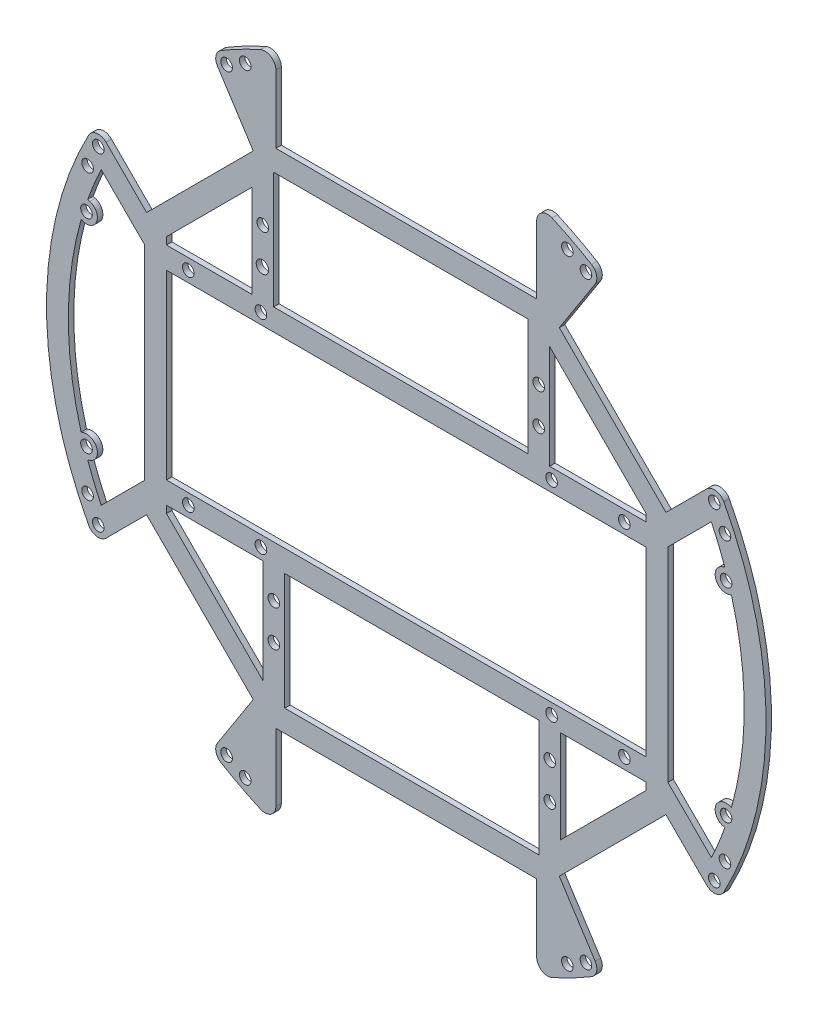
from build123d import *

# Parameters (mm, degrees)
SKETCH1_R            = 1.4
SKETCH1_R_2          = 1.6
SKETCH1_R_3          = 56
BOSS_EXTRUDE2_DEPTH  = 1.5
BOSS_EXTRUDE3_DEPTH  = 1.5
SKETCH3_R            = 1.6
CUT_EXTRUDE1_DEPTH   = 10
SKETCH4_R            = 1.6
BOSS_EXTRUDE4_DEPTH  = 1.5
FILLET1_R            = 3
SKETCH5_R            = 1.6
BOSS_EXTRUDE5_DEPTH  = 1.5
SKETCH6_R            = 1.6
CUT_EXTRUDE2_DEPTH   = 1.5
CUT_EXTRUDE3_DEPTH   = 10
SKETCH8_R            = 1.4
BOSS_EXTRUDE6_DEPTH  = 1.5
SKETCH9_W            = 144
SKETCH9_H            = 6
BOSS_EXTRUDE7_DEPTH  = 1.5
BOSS_EXTRUDE8_DEPTH  = 1.5
SKETCH11_W           = 71.777589622
SKETCH11_H           = 10.305965164
CUT_EXTRUDE4_DEPTH   = 41
SKETCH12_W           = 71.777589622
SKETCH12_H           = 6
BOSS_EXTRUDE9_DEPTH  = 1.5
SKETCH13_W           = 6
SKETCH13_H           = 51.475780146
SKETCH13_H_2         = 46.82423944
BOSS_EXTRUDE10_DEPTH = 1.5
SKETCH14_W           = 66
SKETCH14_H           = 6
CUT_EXTRUDE5_DEPTH   = 41
BOSS_EXTRUDE11_DEPTH = 1.5
SKETCH16_R           = 1.6
CUT_EXTRUDE6_DEPTH   = 5
SKETCH17_R           = 1.6
CUT_EXTRUDE7_DEPTH   = 5
SKETCH18_R           = 1.6
BOSS_EXTRUDE14_DEPTH = 1.5
BOSS_EXTRUDE15_DEPTH = 1.5
SKETCH21_W           = 1.5
SKETCH21_H           = 32.106154556
BOSS_EXTRUDE16_DEPTH = 1.5
SKETCH22_R           = 1.6
SKETCH22_R_2         = 1.7
CUT_EXTRUDE9_DEPTH   = 1.5
BOSS_EXTRUDE17_DEPTH = 1.5
SKETCH24_R           = 1.6
CUT_EXTRUDE10_DEPTH  = 1.5
SKETCH25_R           = 1.6
BOSS_EXTRUDE18_DEPTH = 1.5
SKETCH26_R           = 1.6
CUT_EXTRUDE11_DEPTH  = 1.5
SKETCH28_R           = 1.6
CUT_EXTRUDE12_DEPTH  = 1.5
SKETCH29_R           = 1.6
BOSS_EXTRUDE19_DEPTH = 1.5
SKETCH30_W           = 4.95
SKETCH30_H           = 32.106154556
SKETCH30_W_2         = 1.5
CUT_EXTRUDE13_DEPTH  = 1.5
BOSS_EXTRUDE20_DEPTH = 1.5


with BuildPart() as part:
    # Sketch1 → Boss-Extrude2 (new body)
    with BuildSketch(Plane.XY):
        with BuildLine():
            Line((-35.888794811, 73.41211972), (-35.888794811, 92.265889727))
            ThreePointArc((-35.888794811, 92.265889727), (-42.061063674, 89.620683565), (-48.039811225, 86.563136135))
            Line((-48.039811225, 86.563136135), (-41.888794811, 80.41211972))
            Line((-41.888794811, 80.41211972), (-41.888794811, 65.59143593))
            Line((-41.888794811, 65.59143593), (-53.74011537, 53.74011537))
            Line((-53.74011537, 53.74011537), (-65.053823869, 42.426406871))
            Line((-65.053823869, 42.426406871), (-71.46564447, 36.01458627))
            Line((-71.46564447, 36.01458627), (-82.641648571, 47.190590371))
            ThreePointArc((-82.641648571, 47.190590371), (-85.206397148, 48.036317618), (-87.411811693, 46.477684716))
            ThreePointArc((-87.411811693, 46.477684716), (-99, 0), (-87.411811693, -46.477684716))
            ThreePointArc((-87.411811693, -46.477684716), (-85.206397148, -48.036317618), (-82.641648571, -47.190590371))
            Line((-82.641648571, -47.190590371), (-71.46564447, -36.01458627))
            Line((-71.46564447, -36.01458627), (-65.053823869, -42.426406871))
            Line((-65.053823869, -42.426406871), (-53.74011537, -53.74011537))
            Line((-53.74011537, -53.74011537), (-41.888794811, -65.59143593))
            Line((-41.888794811, -65.59143593), (-41.888794811, -80.41211972))
            Line((-41.888794811, -80.41211972), (-48.039811225, -86.563136135))
            ThreePointArc((-48.039811225, -86.563136135), (-42.061063674, -89.620683565), (-35.888794811, -92.265889727))
            Line((-35.888794811, -92.265889727), (-35.888794811, -73.41211972))
            Line((-35.888794811, -73.41211972), (35.888794811, -73.41211972))
            Line((35.888794811, -73.41211972), (35.888794811, -92.265889727))
            ThreePointArc((35.888794811, -92.265889727), (42.061063674, -89.620683565), (48.039811225, -86.563136135))
            Line((48.039811225, -86.563136135), (41.888794811, -80.41211972))
            Line((41.888794811, -80.41211972), (41.888794811, -65.59143593))
            Line((41.888794811, -65.59143593), (53.74011537, -53.74011537))
            Line((53.74011537, -53.74011537), (65.053823869, -42.426406871))
            Line((65.053823869, -42.426406871), (71.46564447, -36.01458627))
            Line((71.46564447, -36.01458627), (82.641648571, -47.190590371))
            ThreePointArc((82.641648571, -47.190590371), (85.206397148, -48.036317618), (87.411811693, -46.477684716))
            ThreePointArc((87.411811693, -46.477684716), (99, 0), (87.411811693, 46.477684716))
            ThreePointArc((87.411811693, 46.477684716), (85.206397148, 48.036317618), (82.641648571, 47.190590371))
            Line((82.641648571, 47.190590371), (71.46564447, 36.01458627))
            Line((71.46564447, 36.01458627), (65.053823869, 42.426406871))
            Line((65.053823869, 42.426406871), (53.74011537, 53.74011537))
            Line((53.74011537, 53.74011537), (41.888794811, 65.59143593))
            Line((41.888794811, 65.59143593), (41.888794811, 80.41211972))
            Line((41.888794811, 80.41211972), (48.039811225, 86.563136135))
            ThreePointArc((48.039811225, 86.563136135), (42.061063674, 89.620683565), (35.888794811, 92.265889727))
            Line((35.888794811, 92.265889727), (35.888794811, 73.41211972))
            Line((35.888794811, 73.41211972), (-35.888794811, 73.41211972))
        make_face()
        with Locations((-36.062445841, 54.447222151)):
            Circle(SKETCH1_R, mode=Mode.SUBTRACT)
        with Locations((-54.447222151, 36.062445841)):
            Circle(SKETCH1_R, mode=Mode.SUBTRACT)
        with Locations((-60.104076401, 41.71930009)):
            Circle(SKETCH1_R, mode=Mode.SUBTRACT)
        with Locations((-41.71930009, 60.104076401)):
            Circle(SKETCH1_R, mode=Mode.SUBTRACT)
        with Locations((41.365746699, 41.365746699)):
            Circle(SKETCH1_R_2, mode=Mode.SUBTRACT)
        with Locations((41.71930009, 60.104076401)):
            Circle(SKETCH1_R, mode=Mode.SUBTRACT)
        with Locations((60.104076401, 41.71930009)):
            Circle(SKETCH1_R, mode=Mode.SUBTRACT)
        with Locations((54.447222151, 36.062445841)):
            Circle(SKETCH1_R, mode=Mode.SUBTRACT)
        Circle(SKETCH1_R_3, mode=Mode.SUBTRACT)
        with Locations((36.062445841, 54.447222151)):
            Circle(SKETCH1_R, mode=Mode.SUBTRACT)
        with Locations((-40.571353127, 87.005547556)):
            Circle(SKETCH1_R_2, mode=Mode.SUBTRACT)
        with Locations((40.571353127, -87.005547556)):
            Circle(SKETCH1_R_2, mode=Mode.SUBTRACT)
        with Locations((-40.571353127, -87.005547556)):
            Circle(SKETCH1_R_2, mode=Mode.SUBTRACT)
        with Locations((41.365746699, -41.365746699)):
            Circle(SKETCH1_R_2, mode=Mode.SUBTRACT)
        with Locations((-41.365746699, 41.365746699)):
            Circle(SKETCH1_R_2, mode=Mode.SUBTRACT)
        with Locations((-84.762968914, 45.069270027)):
            Circle(SKETCH1_R_2, mode=Mode.SUBTRACT)
        with Locations((-41.365746699, -41.365746699)):
            Circle(SKETCH1_R_2, mode=Mode.SUBTRACT)
        with Locations((84.762968914, 45.069270027)):
            Circle(SKETCH1_R_2, mode=Mode.SUBTRACT)
        with Locations((40.571353127, 87.005547556)):
            Circle(SKETCH1_R_2, mode=Mode.SUBTRACT)
        with Locations((36.062445841, -54.447222151)):
            Circle(SKETCH1_R, mode=Mode.SUBTRACT)
        with Locations((54.447222151, -36.062445841)):
            Circle(SKETCH1_R, mode=Mode.SUBTRACT)
        with Locations((60.104076401, -41.71930009)):
            Circle(SKETCH1_R, mode=Mode.SUBTRACT)
        with Locations((41.71930009, -60.104076401)):
            Circle(SKETCH1_R, mode=Mode.SUBTRACT)
        with Locations((-41.71930009, -60.104076401)):
            Circle(SKETCH1_R, mode=Mode.SUBTRACT)
        with Locations((-60.104076401, -41.71930009)):
            Circle(SKETCH1_R, mode=Mode.SUBTRACT)
        with Locations((-54.447222151, -36.062445841)):
            Circle(SKETCH1_R, mode=Mode.SUBTRACT)
        with Locations((-36.062445841, -54.447222151)):
            Circle(SKETCH1_R, mode=Mode.SUBTRACT)
        with Locations((84.762968914, -45.069270027)):
            Circle(SKETCH1_R_2, mode=Mode.SUBTRACT)
        with Locations((-84.762968914, -45.069270027)):
            Circle(SKETCH1_R_2, mode=Mode.SUBTRACT)
        with BuildLine():
            Line((-56.568542495, 42.426406871), (-49.621038435, 35.478902811))
            ThreePointArc((-49.621038435, 35.478902811), (-43.133513652, 43.133513652), (-35.478902811, 49.621038435))
            Line((-35.478902811, 49.621038435), (-42.426406871, 56.568542495))
            Line((-42.426406871, 56.568542495), (-56.568542495, 42.426406871))
        make_face(mode=Mode.SUBTRACT)
        with BuildLine():
            Line((-57.337431152, 34.710014154), (-52.937019276, 30.309602278))
            ThreePointArc((-52.937019276, 30.309602278), (-61, 0), (-52.937019276, -30.309602278))
            Line((-52.937019276, -30.309602278), (-57.337431152, -34.710014154))
            Line((-57.337431152, -34.710014154), (-60.811183182, -38.183766184))
            Line((-60.811183182, -38.183766184), (-71.46564447, -27.529304896))
            Line((-71.46564447, -27.529304896), (-83.951228087, -40.014888513))
            ThreePointArc((-83.951228087, -40.014888513), (-93, 0), (-83.951228087, 40.014888513))
            Line((-83.951228087, 40.014888513), (-71.46564447, 27.529304896))
            Line((-71.46564447, 27.529304896), (-60.811183182, 38.183766184))
            Line((-60.811183182, 38.183766184), (-57.337431152, 34.710014154))
        make_face(mode=Mode.SUBTRACT)
        with BuildLine():
            Line((-35.888794811, 67.41211972), (-35.888794811, 58.516211808))
            Line((-35.888794811, 58.516211808), (-30.309602278, 52.937019275))
            ThreePointArc((-30.309602278, 52.937019275), (0, 61), (30.309602278, 52.937019275))
            Line((30.309602278, 52.937019275), (35.888794811, 58.516211808))
            Line((35.888794811, 58.516211808), (35.888794811, 67.41211972))
            Line((35.888794811, 67.41211972), (0, 67.41211972))
            Line((0, 67.41211972), (-35.888794811, 67.41211972))
        make_face(mode=Mode.SUBTRACT)
        with BuildLine():
            Line((60.811183182, 38.183766184), (71.46564447, 27.529304896))
            Line((71.46564447, 27.529304896), (83.951228087, 40.014888513))
            ThreePointArc((83.951228087, 40.014888513), (93, 0), (83.951228087, -40.014888513))
            Line((83.951228087, -40.014888513), (71.46564447, -27.529304896))
            Line((71.46564447, -27.529304896), (60.811183182, -38.183766184))
            Line((60.811183182, -38.183766184), (57.337431152, -34.710014154))
            Line((57.337431152, -34.710014154), (52.937019276, -30.309602278))
            ThreePointArc((52.937019276, -30.309602278), (61, 0), (52.937019276, 30.309602278))
            Line((52.937019276, 30.309602278), (57.337431152, 34.710014154))
            Line((57.337431152, 34.710014154), (60.811183182, 38.183766184))
        make_face(mode=Mode.SUBTRACT)
        with BuildLine():
            Line((42.426406871, 56.568542495), (56.568542495, 42.426406871))
            Line((56.568542495, 42.426406871), (49.621038435, 35.478902811))
            ThreePointArc((49.621038435, 35.478902811), (43.133513652, 43.133513652), (35.478902811, 49.621038435))
            Line((35.478902811, 49.621038435), (42.426406871, 56.568542495))
        make_face(mode=Mode.SUBTRACT)
        with BuildLine():
            Line((0, -67.41211972), (35.888794811, -67.41211972))
            Line((35.888794811, -67.41211972), (35.888794811, -58.516211808))
            Line((35.888794811, -58.516211808), (30.309602278, -52.937019275))
            ThreePointArc((30.309602278, -52.937019275), (0, -61), (-30.309602278, -52.937019275))
            Line((-30.309602278, -52.937019275), (-35.888794811, -58.516211808))
            Line((-35.888794811, -58.516211808), (-35.888794811, -67.41211972))
            Line((-35.888794811, -67.41211972), (0, -67.41211972))
        make_face(mode=Mode.SUBTRACT)
        with BuildLine():
            Line((56.568542495, -42.426406871), (49.621038435, -35.478902811))
            ThreePointArc((49.621038435, -35.478902811), (43.133513652, -43.133513652), (35.478902811, -49.621038435))
            Line((35.478902811, -49.621038435), (42.426406871, -56.568542495))
            Line((42.426406871, -56.568542495), (56.568542495, -42.426406871))
        make_face(mode=Mode.SUBTRACT)
        with BuildLine():
            Line((-42.426406871, -56.568542495), (-56.568542495, -42.426406871))
            Line((-56.568542495, -42.426406871), (-49.621038435, -35.478902811))
            ThreePointArc((-49.621038435, -35.478902811), (-43.133513652, -43.133513652), (-35.478902811, -49.621038435))
            Line((-35.478902811, -49.621038435), (-42.426406871, -56.568542495))
        make_face(mode=Mode.SUBTRACT)
    extrude(amount=BOSS_EXTRUDE2_DEPTH)

    # Sketch2 → Boss-Extrude3 (add)
    with BuildSketch(Plane.XY.offset(1.5)):
        with BuildLine():
            Line((-41.888794811, 80.41211972), (-41.888794811, 78.41211972))
            Line((-41.888794811, 78.41211972), (-49.31800671, 85.841331619))
            ThreePointArc((-49.31800671, 85.841331619), (-47.440229793, 86.893179233), (-45.540030314, 87.903956902))
            Line((-45.540030314, 87.903956902), (-41.888794811, 84.252721398))
            Line((-41.888794811, 84.252721398), (-41.888794811, 80.41211972))
        make_face()
        with BuildLine():
            Line((41.888794811, 84.252721398), (45.540030314, 87.903956902))
            ThreePointArc((45.540030314, 87.903956902), (47.440229793, 86.893179233), (49.31800671, 85.841331619))
            Line((49.31800671, 85.841331619), (41.888794811, 78.41211972))
            Line((41.888794811, 78.41211972), (41.888794811, 80.41211972))
            Line((41.888794811, 80.41211972), (41.888794811, 84.252721398))
        make_face()
        with BuildLine():
            Line((41.888794811, -80.41211972), (41.888794811, -78.41211972))
            Line((41.888794811, -78.41211972), (49.31800671, -85.841331619))
            ThreePointArc((49.31800671, -85.841331619), (47.440229793, -86.893179233), (45.540030314, -87.903956902))
            Line((45.540030314, -87.903956902), (41.888794811, -84.252721398))
            Line((41.888794811, -84.252721398), (41.888794811, -80.41211972))
        make_face()
        with BuildLine():
            Line((-41.888794811, -84.252721398), (-45.540030314, -87.903956902))
            ThreePointArc((-45.540030314, -87.903956902), (-47.440229793, -86.893179233), (-49.31800671, -85.841331619))
            Line((-49.31800671, -85.841331619), (-41.888794811, -78.41211972))
            Line((-41.888794811, -78.41211972), (-41.888794811, -80.41211972))
            Line((-41.888794811, -80.41211972), (-41.888794811, -84.252721398))
        make_face()
    extrude(amount=-BOSS_EXTRUDE3_DEPTH)

    # Sketch3 → Cut-Extrude1 (cut)
    with BuildSketch(Plane.XY.offset(1.5)):
        with Locations((-44.327866871, 85.153039985)):
            Circle(SKETCH3_R)
        with Locations((44.327866871, 85.153039985)):
            Circle(SKETCH3_R)
        with Locations((44.327866871, -85.153039985)):
            Circle(SKETCH3_R)
        with Locations((-44.327866871, -85.153039985)):
            Circle(SKETCH3_R)
    extrude(amount=-CUT_EXTRUDE1_DEPTH, mode=Mode.SUBTRACT)

    # Sketch4 → Boss-Extrude4 (add)
    with BuildSketch(Plane.XY.offset(1.5)):
        with Locations((-40.571353127, 87.005547556)):
            Circle(SKETCH4_R)
        with Locations((40.571353127, 87.005547556)):
            Circle(SKETCH4_R)
        with Locations((40.571353127, -87.005547556)):
            Circle(SKETCH4_R)
        with Locations((-40.571353127, -87.005547556)):
            Circle(SKETCH4_R)
    extrude(amount=-BOSS_EXTRUDE4_DEPTH)

    # Fillet1
    fillet1_edges = [part.edges().sort_by_distance(p)[0] for p in [
        (35.888794811, -92.265889727, 0.75),
        (-35.888794811, -92.265889727, 0.75),
        (-35.888794811, 92.265889727, 0.75),
        (35.888794811, 92.265889727, 0.75),
        (49.31800671, 85.841331619, 0.75),
        (-49.31800671, 85.841331619, 0.75),
        (49.31800671, -85.841331619, 0.75),
        (-49.31800671, -85.841331619, 0.75),
    ]]
    fillet(fillet1_edges, radius=FILLET1_R)

    # Sketch5 → Boss-Extrude5 (add)
    with BuildSketch(Plane.XY.offset(1.5)):
        with BuildLine():
            ThreePointArc((-7, 66.41211972), (-10, 63.41211972), (-13, 66.41211972))
            Line((-13, 66.41211972), (-13, 67.41211972))
            Line((-13, 67.41211972), (-9.775161328, 70.187281048))
            Line((-9.775161328, 70.187281048), (-7, 67.41211972))
            Line((-7, 67.41211972), (-7, 66.41211972))
        make_face()
        with Locations((-10, 66.41211972)):
            Circle(SKETCH5_R, mode=Mode.SUBTRACT)
        with BuildLine():
            Line((7, 66.41211972), (7, 67.41211972))
            Line((7, 67.41211972), (9.775161328, 70.187281048))
            Line((9.775161328, 70.187281048), (13, 67.41211972))
            Line((13, 67.41211972), (13, 66.41211972))
            ThreePointArc((13, 66.41211972), (10, 63.41211972), (7, 66.41211972))
        make_face()
        with Locations((10, 66.41211972)):
            Circle(SKETCH5_R, mode=Mode.SUBTRACT)
        with BuildLine():
            ThreePointArc((7, -66.41211972), (10, -63.41211972), (13, -66.41211972))
            Line((13, -66.41211972), (13, -67.41211972))
            Line((13, -67.41211972), (9.775161328, -70.187281048))
            Line((9.775161328, -70.187281048), (7, -67.41211972))
            Line((7, -67.41211972), (7, -66.41211972))
        make_face()
        with Locations((10, -66.41211972)):
            Circle(SKETCH5_R, mode=Mode.SUBTRACT)
        with BuildLine():
            Line((-7, -66.41211972), (-7, -67.41211972))
            Line((-7, -67.41211972), (-9.775161328, -70.187281048))
            Line((-9.775161328, -70.187281048), (-13, -67.41211972))
            Line((-13, -67.41211972), (-13, -66.41211972))
            ThreePointArc((-13, -66.41211972), (-10, -63.41211972), (-7, -66.41211972))
        make_face()
        with Locations((-10, -66.41211972)):
            Circle(SKETCH5_R, mode=Mode.SUBTRACT)
    extrude(amount=-BOSS_EXTRUDE5_DEPTH)

    # Sketch6 → Cut-Extrude2 (cut)
    with BuildSketch(Plane.XY.offset(1.5)):
        with Locations((-10, -66.41211972)):
            Circle(SKETCH6_R)
        with Locations((10, -66.41211972)):
            Circle(SKETCH6_R)
        with Locations((10, 66.41211972)):
            Circle(SKETCH6_R)
        with Locations((-10, 66.41211972)):
            Circle(SKETCH6_R)
    extrude(amount=-CUT_EXTRUDE2_DEPTH, mode=Mode.SUBTRACT)

    # Sketch7 → Cut-Extrude3 (cut)
    with BuildSketch(Plane.XY.offset(1.5)):
        Polygon((-71.46564447, 27.529304896), (-31.582829646, 67.41211972), (31.582829646, 67.41211972), (71.46564447, 27.529304896), (71.46564447, -27.529304896), (31.582829646, -67.41211972), (-31.582829646, -67.41211972), (-71.46564447, -27.529304896), align=None)
    extrude(amount=-CUT_EXTRUDE3_DEPTH, mode=Mode.SUBTRACT)

    # Sketch8 → Boss-Extrude6 (add)
    with BuildSketch(Plane.XY.offset(1.5)):
        with Locations((-60.104076401, -41.71930009)):
            Circle(SKETCH8_R)
        with Locations((-41.71930009, -60.104076401)):
            Circle(SKETCH8_R)
        with Locations((-60.104076401, 41.71930009)):
            Circle(SKETCH8_R)
        with Locations((-41.71930009, 60.104076401)):
            Circle(SKETCH8_R)
        with Locations((41.71930009, 60.104076401)):
            Circle(SKETCH8_R)
        with Locations((60.104076401, 41.71930009)):
            Circle(SKETCH8_R)
        with Locations((60.104076401, -41.71930009)):
            Circle(SKETCH8_R)
        with Locations((41.71930009, -60.104076401)):
            Circle(SKETCH8_R)
        Polygon((-23.568897205, -67.41211972), (23.568897205, -67.41211972), (18.047381119, -71.229666129), (-16.662853075, -71.229666129), align=None)
        Polygon((23.568897205, 67.41211972), (-26.29313108, 67.41211972), (-20.11587514, 71.683041123), (11.2489996, 71.683041123), align=None)
    extrude(amount=-BOSS_EXTRUDE6_DEPTH)

    # Sketch9 → Boss-Extrude7 (add)
    with BuildSketch(Plane.XY.offset(1.5)):
        with Locations((0, 26.41211972)):
            Rectangle(SKETCH9_W, SKETCH9_H)
        with Locations((0, -26.41211972)):
            Rectangle(SKETCH9_W, SKETCH9_H)
    extrude(amount=-BOSS_EXTRUDE7_DEPTH)

    # Sketch10 → Boss-Extrude8 (add)
    with BuildSketch(Plane.XY.offset(1.5)):
        Polygon((-72, 23.41211972), (-66, 23.41211972), (-66, 35.490217447), (-72, 28.063660426), align=None)
        Polygon((72, 28.063660426), (72, 23.41211972), (66, 23.41211972), (66, 35.490217447), align=None)
        Polygon((72, -23.41211972), (66, -23.41211972), (66, -35.490217447), (72, -28.063660426), align=None)
        Polygon((-72, -28.063660426), (-72, -23.41211972), (-66, -23.41211972), (-66, -35.490217447), align=None)
    extrude(amount=-BOSS_EXTRUDE8_DEPTH)

    # Sketch11 → Cut-Extrude4 (cut)
    with BuildSketch(Plane.XY.offset(1.5)):
        with Locations((0, 68.259137138)):
            Rectangle(SKETCH11_W, SKETCH11_H)
        with Locations((0, -68.259137138)):
            Rectangle(SKETCH11_W, SKETCH11_H)
    extrude(amount=-CUT_EXTRUDE4_DEPTH, mode=Mode.SUBTRACT)

    # Sketch12 → Boss-Extrude9 (add)
    with BuildSketch(Plane.XY.offset(1.5)):
        with Locations((0, 66.106154556)):
            Rectangle(SKETCH12_W, SKETCH12_H)
        with Locations((0, -66.106154556)):
            Rectangle(SKETCH12_W, SKETCH12_H)
    extrude(amount=-BOSS_EXTRUDE9_DEPTH)

    # Sketch13 → Boss-Extrude10 (add)
    with BuildSketch(Plane.XY.offset(1.5)):
        with Locations((-69, -2.325770353)):
            Rectangle(SKETCH13_W, SKETCH13_H)
        with Locations((69, 0)):
            Rectangle(SKETCH13_W, SKETCH13_H_2)
    extrude(amount=-BOSS_EXTRUDE10_DEPTH)

    # Sketch14 → Cut-Extrude5 (cut)
    with BuildSketch(Plane.XY.offset(1.5)):
        with Locations((33, 26.41211972)):
            Rectangle(SKETCH14_W, SKETCH14_H)
        with Locations((-33, 26.41211972)):
            Rectangle(SKETCH14_W, SKETCH14_H)
        with Locations((-33, -26.41211972)):
            Rectangle(SKETCH14_W, SKETCH14_H)
        with Locations((33, -26.41211972)):
            Rectangle(SKETCH14_W, SKETCH14_H)
    extrude(amount=-CUT_EXTRUDE5_DEPTH, mode=Mode.SUBTRACT)

    # Sketch15 → Boss-Extrude11 (add)
    with BuildSketch(Plane.XY.offset(1.5)):
        Polygon((-66, -25), (0, -25), (66, -25), (66, -31), (-66, -31), align=None)
        Polygon((0, 25), (66, 25), (66, 31), (-66, 31), (-66, 25), align=None)
    extrude(amount=-BOSS_EXTRUDE11_DEPTH)

    # Sketch16 → Cut-Extrude6 (cut)
    with BuildSketch(Plane.XY.offset(1.5)):
        with Locations((60, 28)):
            Circle(SKETCH16_R)
        with Locations((-60, 28)):
            Circle(SKETCH16_R)
        with Locations((-60, -28)):
            Circle(SKETCH16_R)
        with Locations((60, -28)):
            Circle(SKETCH16_R)
    extrude(amount=-CUT_EXTRUDE6_DEPTH, mode=Mode.SUBTRACT)

    # Sketch17 → Cut-Extrude7 (cut)
    with BuildSketch(Plane.XY.offset(1.5)):
        with Locations((-40, 28)):
            Circle(SKETCH17_R)
        with Locations((40, 28)):
            Circle(SKETCH17_R)
        with Locations((40, -28)):
            Circle(SKETCH17_R)
        with Locations((-40, -28)):
            Circle(SKETCH17_R)
    extrude(amount=-CUT_EXTRUDE7_DEPTH, mode=Mode.SUBTRACT)

    # Sketch18 → Boss-Extrude14 (add)
    with BuildSketch(Plane.XY.offset(1.5)):
        Polygon((34.5, 63.106154556), (34.5, 31), (31.5, 31), (28.5, 31), (28.5, 63.106154556), align=None)
        with Locations((31.5, 49)):
            Circle(SKETCH18_R, mode=Mode.SUBTRACT)
        with Locations((31.5, 39)):
            Circle(SKETCH18_R, mode=Mode.SUBTRACT)
        Polygon((-34.5, -63.106154556), (-34.5, -31), (-31.5, -31), (-28.5, -31), (-28.5, -63.106154556), align=None)
        with Locations((-31.5, -49)):
            Circle(SKETCH18_R, mode=Mode.SUBTRACT)
        with Locations((-31.5, -39)):
            Circle(SKETCH18_R, mode=Mode.SUBTRACT)
    extrude(amount=-BOSS_EXTRUDE14_DEPTH)

    # Sketch19 → Boss-Extrude15 (add)
    with BuildSketch(Plane.XY.offset(1.5)):
        Polygon((-38, 31), (-35, 31), (-35, 63.106154556), (-35.888794811, 63.106154556), (-41, 57.994949366), (-41, 31), align=None)
        with BuildLine():
            ThreePointArc((-36.4, 39), (-36.86862915, 37.86862915), (-38, 37.4))
            ThreePointArc((-38, 37.4), (-39.6, 39), (-38, 40.6))
            ThreePointArc((-38, 40.6), (-36.86862915, 40.13137085), (-36.4, 39))
        make_face(mode=Mode.SUBTRACT)
        with BuildLine():
            ThreePointArc((-36.4, 49), (-36.86862915, 47.86862915), (-38, 47.4))
            ThreePointArc((-38, 47.4), (-39.13137085, 50.13137085), (-36.4, 49))
        make_face(mode=Mode.SUBTRACT)
        Polygon((38, -31), (35, -31), (35, -63.106154556), (35.888794811, -63.106154556), (41, -57.994949366), (41, -31), align=None)
        with BuildLine():
            ThreePointArc((39.6, -49), (36.86862915, -50.13137085), (38, -47.4))
            ThreePointArc((38, -47.4), (39.13137085, -47.86862915), (39.6, -49))
        make_face(mode=Mode.SUBTRACT)
        with BuildLine():
            ThreePointArc((38, -40.6), (36.4, -39), (38, -37.4))
            ThreePointArc((38, -37.4), (39.13137085, -37.86862915), (39.6, -39))
            ThreePointArc((39.6, -39), (39.13137085, -40.13137085), (38, -40.6))
        make_face(mode=Mode.SUBTRACT)
    extrude(amount=-BOSS_EXTRUDE15_DEPTH)

    # Sketch21 → Boss-Extrude16 (add)
    with BuildSketch(Plane.XY.offset(1.5)):
        with BuildLine():
            ThreePointArc((-32.25, -40.413329403), (-31.4, -39), (-32.25, -37.586670597))
            ThreePointArc((-32.25, -37.586670597), (-29.9, -39), (-32.25, -40.413329403))
        make_face()
        with BuildLine():
            ThreePointArc((-32.25, -50.413329403), (-31.4, -49), (-32.25, -47.586670597))
            ThreePointArc((-32.25, -47.586670597), (-29.9, -49), (-32.25, -50.413329403))
        make_face()
        with Locations((-35.25, -47.053077278)):
            Rectangle(SKETCH21_W, SKETCH21_H)
        Polygon((42.5, -56.494949366), (41, -57.994949366), (41, -31), (42.5, -31), align=None)
        with BuildLine():
            ThreePointArc((38.75, -50.413329403), (36.4, -49), (38.75, -47.586670597))
            ThreePointArc((38.75, -47.586670597), (37.9, -49), (38.75, -50.413329403))
        make_face()
        with BuildLine():
            ThreePointArc((38.75, -40.413329403), (36.4, -39), (38.75, -37.586670597))
            ThreePointArc((38.75, -37.586670597), (37.9, -39), (38.75, -40.413329403))
        make_face()
        with Locations((35.25, 47.053077278)):
            Rectangle(SKETCH21_W, SKETCH21_H)
        with BuildLine():
            ThreePointArc((32.25, 47.586670597), (29.9, 49), (32.25, 50.413329403))
            ThreePointArc((32.25, 50.413329403), (31.4, 49), (32.25, 47.586670597))
        make_face()
        with BuildLine():
            ThreePointArc((32.25, 37.586670597), (29.9, 39), (32.25, 40.413329403))
            ThreePointArc((32.25, 40.413329403), (31.4, 39), (32.25, 37.586670597))
        make_face()
        with BuildLine():
            ThreePointArc((-38.75, 47.586670597), (-37.9, 49), (-38.75, 50.413329403))
            ThreePointArc((-38.75, 50.413329403), (-36.4, 49), (-38.75, 47.586670597))
        make_face()
        with BuildLine():
            ThreePointArc((-38.75, 37.586670597), (-37.9, 39), (-38.75, 40.413329403))
            ThreePointArc((-38.75, 40.413329403), (-36.4, 39), (-38.75, 37.586670597))
        make_face()
        Polygon((-41, 57.994949366), (-41, 31), (-42.5, 31), (-42.5, 56.494949366), align=None)
    extrude(amount=-BOSS_EXTRUDE16_DEPTH)

    # Sketch22 → Cut-Extrude9 (cut)
    with BuildSketch(Plane.XY.offset(1.5)):
        with Locations((-39.5, 49)):
            Circle(SKETCH22_R)
        with Locations((-39.6, 39)):
            Circle(SKETCH22_R_2)
        with Locations((33, 49)):
            Circle(SKETCH22_R)
        with Locations((33, 39)):
            Circle(SKETCH22_R)
        with Locations((-33, -39)):
            Circle(SKETCH22_R)
        with Locations((-33, -49)):
            Circle(SKETCH22_R)
        with Locations((39.5, -39)):
            Circle(SKETCH22_R)
        with Locations((39.5, -49)):
            Circle(SKETCH22_R)
    extrude(amount=-CUT_EXTRUDE9_DEPTH, mode=Mode.SUBTRACT)

    # Sketch23 → Boss-Extrude17 (add)
    with BuildSketch(Plane.XY.offset(1.5)):
        Polygon((36, 31), (39.45, 31), (39.45, 59.544949366), (36, 62.994949366), align=None)
        Polygon((-36, -31), (-39.45, -31), (-39.45, -59.544949366), (-36, -62.994949366), align=None)
    extrude(amount=-BOSS_EXTRUDE17_DEPTH)

    # Sketch24 → Cut-Extrude10 (cut)
    with BuildSketch(Plane.XY.offset(1.5)):
        with Locations((-36.45, -49)):
            Circle(SKETCH24_R)
        with Locations((-36.45, -39)):
            Circle(SKETCH24_R)
        with Locations((36.45, 49)):
            Circle(SKETCH24_R)
        with Locations((36.45, 39)):
            Circle(SKETCH24_R)
    extrude(amount=-CUT_EXTRUDE10_DEPTH, mode=Mode.SUBTRACT)

    # Sketch25 → Boss-Extrude18 (add)
    with BuildSketch(Plane.XY.offset(1.5)):
        with BuildLine():
            Line((-93.258777892, -26.525048498), (-91.439555948, -32.242603178))
            Line((-91.439555948, -32.242603178), (-87.090389028, -30.85877734))
            ThreePointArc((-87.090389028, -30.85877734), (-85.14122266, -27.090389028), (-88.909610972, -25.14122266))
            Line((-88.909610972, -25.14122266), (-93.258777892, -26.525048498))
        make_face()
        with Locations((-88, -28)):
            Circle(SKETCH25_R, mode=Mode.SUBTRACT)
        with BuildLine():
            Line((-87.090389028, 30.85877734), (-91.439555948, 32.242603178))
            Line((-91.439555948, 32.242603178), (-93.258777892, 26.525048498))
            Line((-93.258777892, 26.525048498), (-88.909610972, 25.14122266))
            ThreePointArc((-88.909610972, 25.14122266), (-85.14122266, 27.090389028), (-87.090389028, 30.85877734))
        make_face()
        with Locations((-88, 28)):
            Circle(SKETCH25_R, mode=Mode.SUBTRACT)
        with BuildLine():
            Line((87.090389028, -30.85877734), (91.439555948, -32.242603178))
            Line((91.439555948, -32.242603178), (93.258777892, -26.525048498))
            Line((93.258777892, -26.525048498), (88.909610972, -25.14122266))
            ThreePointArc((88.909610972, -25.14122266), (85.14122266, -27.090389028), (87.090389028, -30.85877734))
        make_face()
        with Locations((88, -28)):
            Circle(SKETCH25_R, mode=Mode.SUBTRACT)
        with BuildLine():
            Line((93.258777892, 26.525048498), (91.439555948, 32.242603178))
            Line((91.439555948, 32.242603178), (87.090389028, 30.85877734))
            ThreePointArc((87.090389028, 30.85877734), (85.14122266, 27.090389028), (88.909610972, 25.14122266))
            Line((88.909610972, 25.14122266), (93.258777892, 26.525048498))
        make_face()
        with Locations((88, 28)):
            Circle(SKETCH25_R, mode=Mode.SUBTRACT)
    extrude(amount=-BOSS_EXTRUDE18_DEPTH)

    # Sketch26 → Cut-Extrude11 (cut)
    with BuildSketch(Plane.XY.offset(1.5)):
        with Locations((-88, 28)):
            Circle(SKETCH26_R)
        with Locations((-88, -28)):
            Circle(SKETCH26_R)
        with Locations((88, -28)):
            Circle(SKETCH26_R)
        with Locations((88, 28)):
            Circle(SKETCH26_R)
    extrude(amount=-CUT_EXTRUDE11_DEPTH, mode=Mode.SUBTRACT)

    # Sketch28 → Cut-Extrude12 (cut)
    with BuildSketch(Plane.XY.offset(1.5)):
        with Locations((-87.700363934, 39.046717735)):
            Circle(SKETCH28_R)
        with Locations((87.700363934, 39.046717735)):
            Circle(SKETCH28_R)
        with Locations((87.700363934, -39.046717735)):
            Circle(SKETCH28_R)
        with Locations((-87.700363934, -39.046717735)):
            Circle(SKETCH28_R)
    extrude(amount=-CUT_EXTRUDE12_DEPTH, mode=Mode.SUBTRACT)

    # Sketch29 → Boss-Extrude19 (add)
    with BuildSketch(Plane.XY.offset(1.5)):
        with BuildLine():
            Line((42.598378746, 89.366538079), (38.032036127, 79.786872289))
            Line((38.032036127, 79.786872289), (41.393256923, 64.252993798))
            Line((41.393256923, 64.252993798), (46.575002765, 72.29639768))
            Line((46.575002765, 72.29639768), (51.939928592, 80.62414407))
            Line((51.939928592, 80.62414407), (51.990700761, 80.70295555))
            ThreePointArc((51.990700761, 80.70295555), (52.360123748, 82.991062404), (50.988769416, 84.85956277))
            ThreePointArc((50.988769416, 84.85956277), (46.847804451, 87.214008153), (42.598378746, 89.366538079))
        make_face()
        with Locations((44.327866871, 85.153039985)):
            Circle(SKETCH29_R, mode=Mode.SUBTRACT)
        with Locations((49.443655191, 82.288060867)):
            Circle(SKETCH29_R, mode=Mode.SUBTRACT)
        with BuildLine():
            ThreePointArc((-50.988769416, 84.85956277), (-52.360123748, 82.991062404), (-51.990700761, 80.70295555))
            Line((-51.990700761, 80.70295555), (-51.939928592, 80.62414407))
            Line((-51.939928592, 80.62414407), (-46.575002765, 72.29639768))
            Line((-46.575002765, 72.29639768), (-41.393256923, 64.252993798))
            Line((-41.393256923, 64.252993798), (-38.032036127, 79.786872289))
            Line((-38.032036127, 79.786872289), (-42.598378746, 89.366538079))
            ThreePointArc((-42.598378746, 89.366538079), (-46.847804451, 87.214008153), (-50.988769416, 84.85956277))
        make_face()
        with Locations((-49.443655191, 82.288060867)):
            Circle(SKETCH29_R, mode=Mode.SUBTRACT)
        with Locations((-44.327866871, 85.153039985)):
            Circle(SKETCH29_R, mode=Mode.SUBTRACT)
        with BuildLine():
            Line((-42.598378746, -89.366538079), (-38.032036127, -79.786872289))
            Line((-38.032036127, -79.786872289), (-41.393256923, -64.252993798))
            Line((-41.393256923, -64.252993798), (-46.575002765, -72.29639768))
            Line((-46.575002765, -72.29639768), (-51.939928592, -80.62414407))
            Line((-51.939928592, -80.62414407), (-51.990700761, -80.70295555))
            ThreePointArc((-51.990700761, -80.70295555), (-52.360123748, -82.991062404), (-50.988769416, -84.85956277))
            ThreePointArc((-50.988769416, -84.85956277), (-46.847804451, -87.214008153), (-42.598378746, -89.366538079))
        make_face()
        with Locations((-49.443655191, -82.288060867)):
            Circle(SKETCH29_R, mode=Mode.SUBTRACT)
        with Locations((-44.327866871, -85.153039985)):
            Circle(SKETCH29_R, mode=Mode.SUBTRACT)
        with BuildLine():
            ThreePointArc((50.988769416, -84.85956277), (52.360123748, -82.991062404), (51.990700761, -80.70295555))
            Line((51.990700761, -80.70295555), (51.939928592, -80.62414407))
            Line((51.939928592, -80.62414407), (46.575002765, -72.29639768))
            Line((46.575002765, -72.29639768), (41.393256923, -64.252993798))
            Line((41.393256923, -64.252993798), (38.032036127, -79.786872289))
            Line((38.032036127, -79.786872289), (42.598378746, -89.366538079))
            ThreePointArc((42.598378746, -89.366538079), (46.847804451, -87.214008153), (50.988769416, -84.85956277))
        make_face()
        with Locations((44.327866871, -85.153039985)):
            Circle(SKETCH29_R, mode=Mode.SUBTRACT)
        with Locations((49.443655191, -82.288060867)):
            Circle(SKETCH29_R, mode=Mode.SUBTRACT)
    extrude(amount=-BOSS_EXTRUDE19_DEPTH)

    # Sketch30 → Cut-Extrude13 (cut)
    with BuildSketch(Plane.XY.offset(1.5)):
        with Locations((-30.975, -47.053077278)):
            Rectangle(SKETCH30_W, SKETCH30_H)
        with Locations((35.75, -47.053077278)):
            Rectangle(SKETCH30_W_2, SKETCH30_H)
        with Locations((-35.75, 47.053077278)):
            Rectangle(SKETCH30_W_2, SKETCH30_H)
        with Locations((30.975, 47.053077278)):
            Rectangle(SKETCH30_W, SKETCH30_H)
    extrude(amount=-CUT_EXTRUDE13_DEPTH, mode=Mode.SUBTRACT)

    # Sketch31 → Boss-Extrude20 (add)
    with BuildSketch(Plane.XY.offset(1.5)):
        Polygon((-33.45, -37.464584747), (-33.45, -54.487199965), (-35.24979153, -54.197542826), (-34.606108999, -47.664165134), (-34.927950264, -41.098603317), (-34.516917919, -36.926625012), align=None)
        Polygon((34.796478965, 51.236898102), (34.796478965, 47.17274868), (34.796478965, 35.517074868), (33.45, 32.015260587), (33.45, 51.901475994), align=None)
    extrude(amount=-BOSS_EXTRUDE20_DEPTH)


solid = part.part
